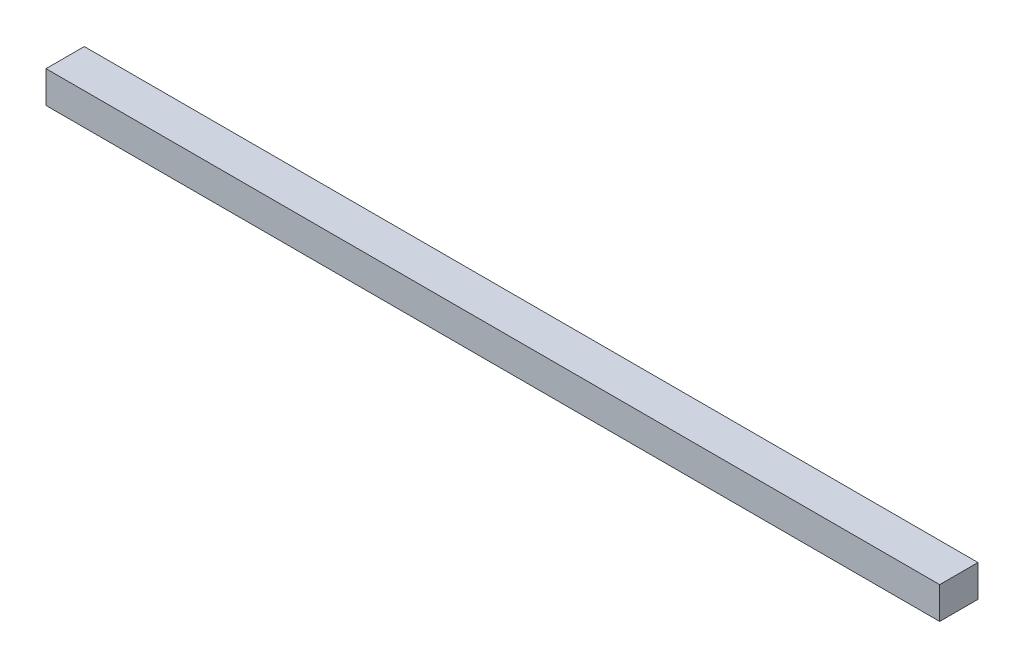
from build123d import *

# Parameters (mm, degrees)
SKETCH1_W           = 30
SKETCH1_H           = 25
BOSS_EXTRUDE1_DEPTH = 700


with BuildPart() as part:
    # Sketch1 → Boss-Extrude1 (new body)
    with BuildSketch(Plane(origin=(0, 0, 0), x_dir=(0, 0, -1), z_dir=(1, 0, 0))):
        with Locations((15, 12.5)):
            Rectangle(SKETCH1_W, SKETCH1_H)
    extrude(amount=BOSS_EXTRUDE1_DEPTH)


solid = part.part
